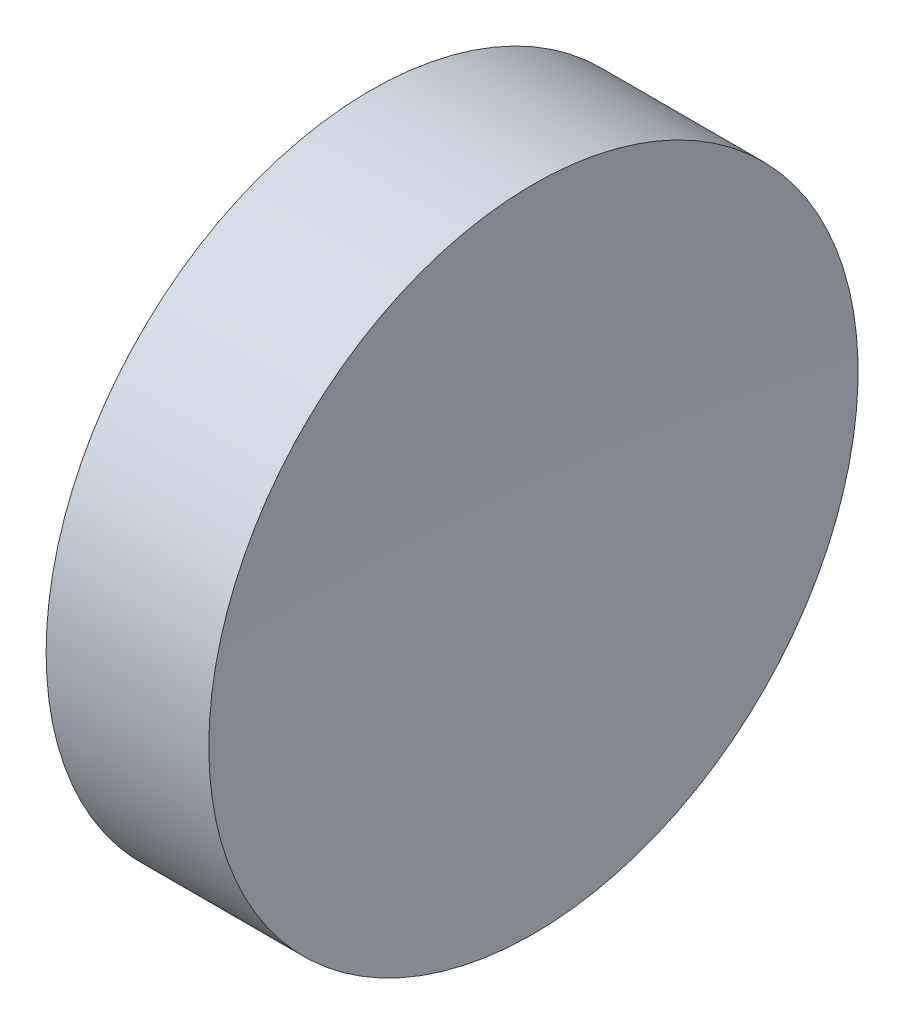
from build123d import *


with BuildPart() as part:
    # 草图1 → 旋转1 (revolve)
    with BuildSketch(Plane(origin=(0, 0, 0), x_dir=(1, 0, 0), z_dir=(0, 1, 0)), mode=Mode.PRIVATE) as revolve_1_sk:
        with BuildLine():
            Line((0, 0), (2.98, 0))
            ThreePointArc((2.98, 0), (3.030466772, 3.176603129), (3.181816149, 6.35))
            Line((3.181816149, 6.35), (0, 6.35))
            Line((0, 6.35), (0, 0))
        make_face()
    revolve(revolve_1_sk.sketch.rotate(Axis((0, 0, 0), (1, 0, 0)), 180), axis=Axis((0, 0, 0), (1, 0, 0)))  # turned: the seam where the file's is


solid = part.part
